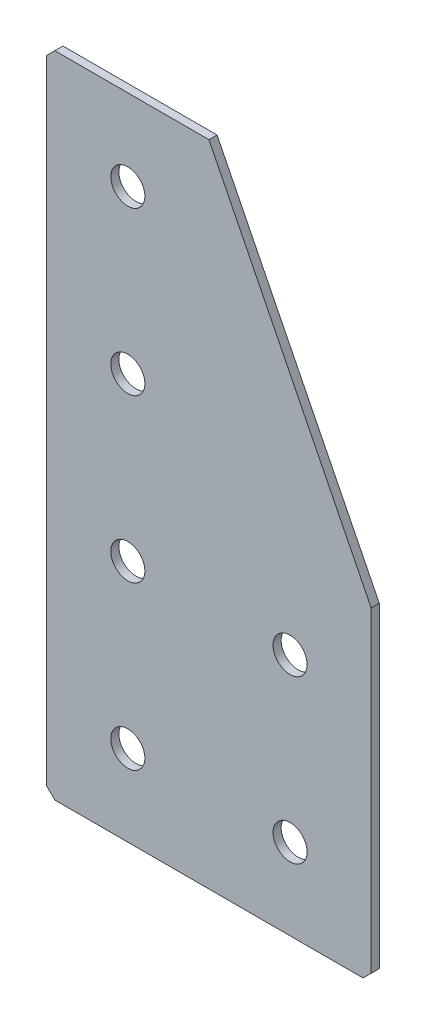
from build123d import *

# Parameters (mm, degrees)
EXTRUDE_1_DEPTH       = 2
HOLE_WIZARD_M81_D     = 8.4
HOLE_WIZARD_M81_DEPTH = 2
CHAMFER_1_SIZE        = 2


with BuildPart() as part:
    # Эскиз1 → Бобышка-Вытянуть1 (new body)
    with BuildSketch(Plane(origin=(0, 0, 0), x_dir=(1, 0, 0), z_dir=(0, 0, -1))):
        Polygon((0, 0), (0, 160), (80, 160), (80, 80), (40, 0), align=None)
    extrude(amount=EXTRUDE_1_DEPTH)

    # Отверстие с зазором M81
    with Locations(Plane(origin=(0, 0, -2), x_dir=(1, 0, 0), z_dir=(0, 0, -1))):
        with Locations((20, 140), (20, 100), (20, 60), (20, 20), (60, 140), (60, 100)):
            Hole(HOLE_WIZARD_M81_D / 2, depth=HOLE_WIZARD_M81_DEPTH)

    # Фаска1
    chamfer_1_edges = [part.edges().sort_by_distance(p)[0] for p in [
        (0, 0, -1),
        (0, -160, -1),
        (80, -160, -1),
    ]]
    chamfer(chamfer_1_edges, length=CHAMFER_1_SIZE)


solid = part.part
